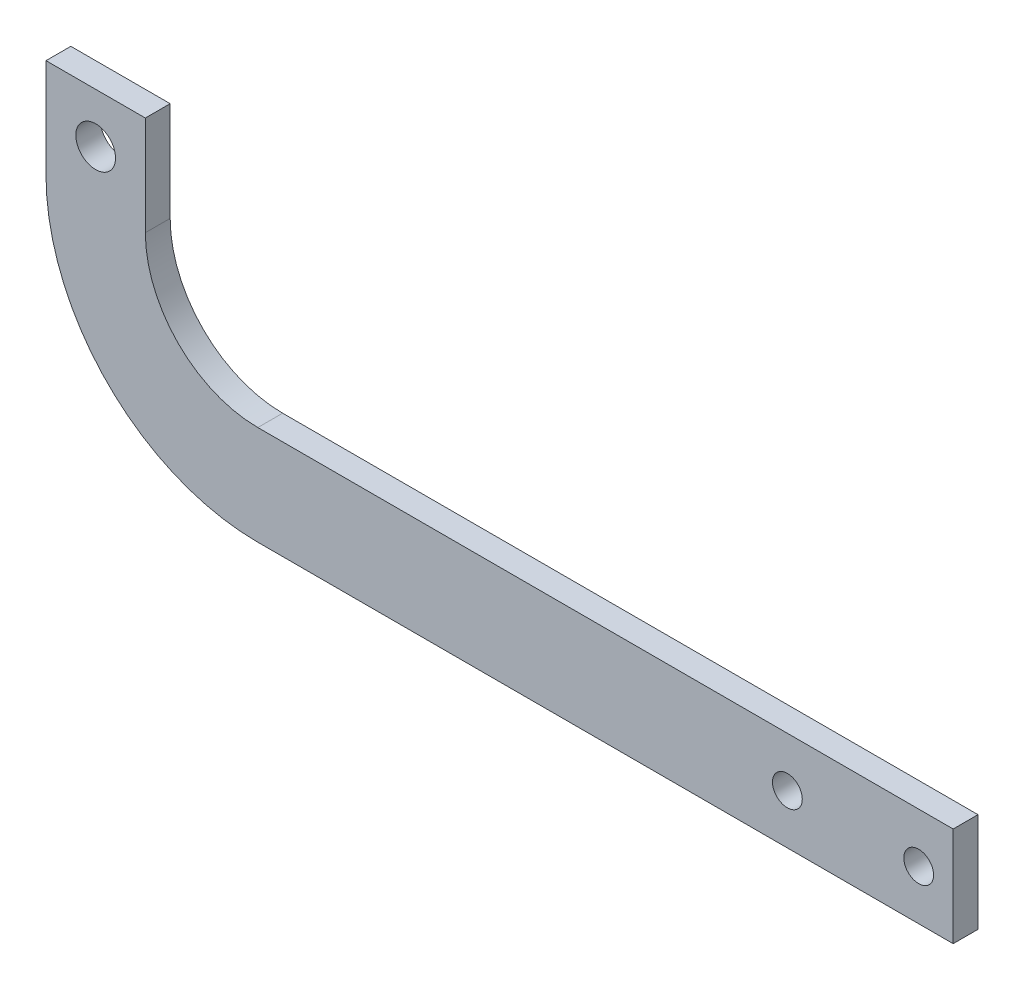
from build123d import *

# Parameters (mm, degrees)
ESQUISSE1_R        = 2
ESQUISSE1_R_2      = 1.5
BOSS_EXTRU_1_DEPTH = 2.5


with BuildPart() as part:
    # Esquisse1 → Boss.-Extru.1 (new body)
    with BuildSketch(Plane.XY):
        with BuildLine():
            Line((0, 0), (70, 0))
            Line((70, 0), (70, 10))
            Line((70, 10), (0, 10))
            ThreePointArc((0, 10), (-8.007101932, 13.316650215), (-11.323752147, 21.323752147))
            Line((-11.323752147, 21.323752147), (-11.323752147, 31.323752147))
            Line((-11.323752147, 31.323752147), (-21.323752147, 31.323752147))
            Line((-21.323752147, 31.323752147), (-21.323752147, 21.323752147))
            ThreePointArc((-21.323752147, 21.323752147), (-15.078169744, 6.245582404), (0, 0))
        make_face()
        with Locations((-16.323752147, 26.323752147)):
            Circle(ESQUISSE1_R, mode=Mode.SUBTRACT)
        with Locations((66.53, 5)):
            Circle(ESQUISSE1_R_2, mode=Mode.SUBTRACT)
        with Locations((53.31, 5)):
            Circle(ESQUISSE1_R_2, mode=Mode.SUBTRACT)
    extrude(amount=BOSS_EXTRU_1_DEPTH)


solid = part.part
